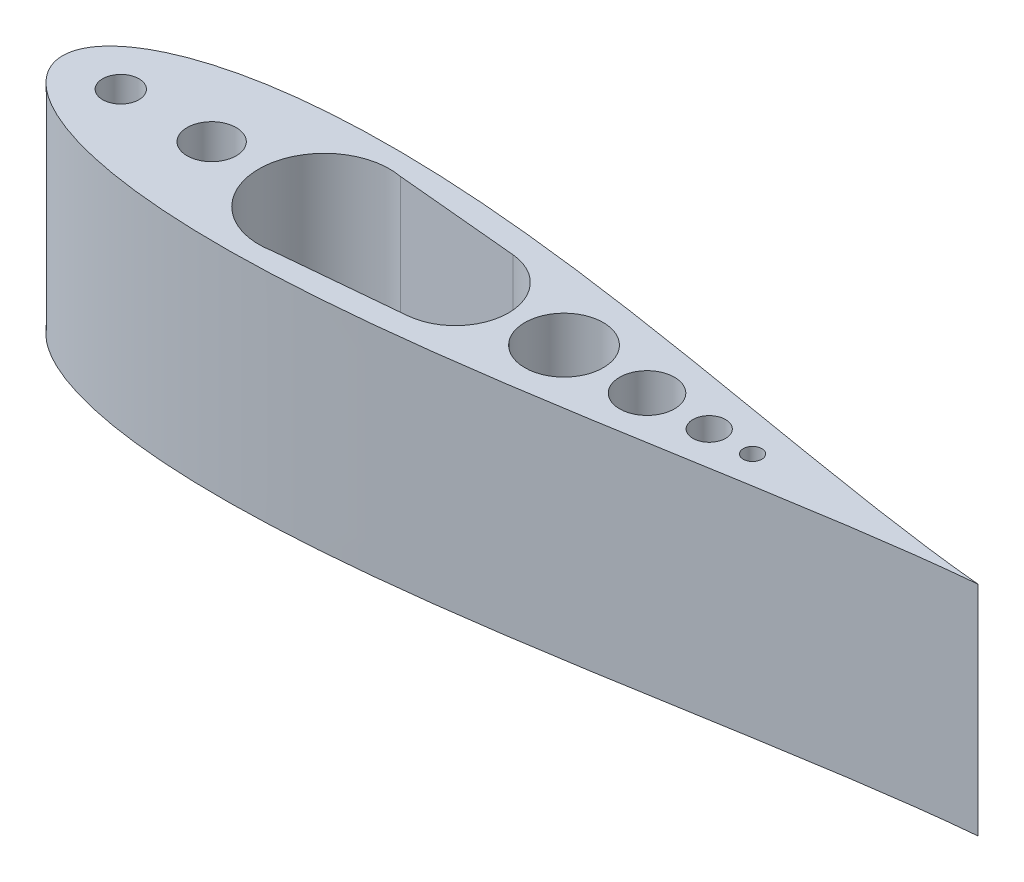
from build123d import *

# Parameters (mm, degrees)
SKETCH1_R           = 5.715
SKETCH1_R_2         = 9.131011462
SKETCH1_R_3         = 6.392333333
SKETCH1_R_4         = 3.81
SKETCH1_R_5         = 2.159
BOSS_EXTRUDE1_DEPTH = 50.8


with BuildPart() as part:
    # Sketch1 → Boss-Extrude1 (new body)
    with BuildSketch(Plane(origin=(0, 0, 0), x_dir=(1, 0, 0), z_dir=(0, 1, 0))):
        with BuildLine():
            add(Edge.make_bspline(
                [(-106.482983395, 7e-09), (-106.481988205, 0.336221447), (-106.427915569, 1.172470852), (-106.105951464, 2.643099269), (-105.314009735, 4.475217408), (-103.897531119, 6.504348419), (-101.808045378, 8.571651332), (-99.066717841, 10.567556704), (-95.719803188, 12.4267473), (-91.817332429, 14.111441711), (-87.406701835, 15.599318162), (-82.531907012, 16.877133323), (-77.234149654, 17.93743562), (-71.552607098, 18.776740572), (-65.525147606, 19.395460586), (-59.188591418, 19.79657403), (-52.57905308, 19.986276316), (-45.732001964, 19.972865837), (-38.682363694, 19.76732247), (-31.464522928, 19.382552478), (-24.112335149, 18.833317467), (-16.659115821, 18.136000968), (-9.137634043, 17.308302017), (-1.580112881, 16.368906014), (5.98177291, 15.337213534), (13.516891029, 14.232999407), (20.994645609, 13.076129848), (28.384968739, 11.886210001), (35.658323251, 10.682336314), (42.785702907, 9.482759124), (49.738647425, 8.304637787), (56.489265684, 7.163760718), (63.010281114, 6.074356699), (69.275076728, 5.048841412), (75.257781106, 4.097692071), (80.933343311, 3.229317249), (86.277669376, 2.449846213), (91.267618323, 1.763292049), (95.881607116, 1.17122476), (100.098099776, 0.673119164), (103.673185129, 0.290516392), (105.83614122, 0.081745654), (106.733370691, 7e-09)],
                knots=[0.5, 0.5, 0.5, 0.5, 0.502166769, 0.505390167, 0.509655974, 0.514947682, 0.521244711, 0.528520886, 0.536744945, 0.54588136, 0.555890751, 0.566730119, 0.57835299, 0.590709588, 0.603747039, 0.617409572, 0.631638768, 0.646373793, 0.661551658, 0.677107483, 0.692974771, 0.709085713, 0.725371443, 0.741762353, 0.758188398, 0.774579367, 0.790865214, 0.806976332, 0.822843867, 0.838400002, 0.853578262, 0.868313774, 0.882543568, 0.896206835, 0.909245173, 0.92160287, 0.933227116, 0.944068236, 0.954079898, 0.963219316, 0.971447445, 0.977251074, 0.977251074, 0.977251074, 0.977251074], degree=3))
            add(Edge.make_bspline(
                [(-106.482983395, -7e-09), (-106.481988205, -0.336221447), (-106.427915569, -1.172470852), (-106.105951463, -2.643099269), (-105.314009735, -4.475217408), (-103.897531118, -6.504348419), (-101.808045378, -8.571651332), (-99.06671784, -10.567556704), (-95.719803188, -12.4267473), (-91.817332429, -14.111441711), (-87.406701835, -15.599318162), (-82.531907011, -16.877133323), (-77.234149654, -17.93743562), (-71.552607098, -18.776740572), (-65.525147605, -19.395460586), (-59.188591417, -19.79657403), (-52.57905308, -19.986276316), (-45.732001964, -19.972865837), (-38.682363694, -19.76732247), (-31.464522928, -19.382552478), (-24.112335148, -18.833317467), (-16.659115821, -18.136000968), (-9.137634043, -17.308302017), (-1.580112881, -16.368906014), (5.98177291, -15.337213534), (13.516891029, -14.232999407), (20.99464561, -13.076129848), (28.384968739, -11.886210001), (35.658323251, -10.682336314), (42.785702907, -9.482759124), (49.738647426, -8.304637787), (56.489265684, -7.163760718), (63.010281115, -6.074356699), (69.275076728, -5.048841412), (75.257781106, -4.097692071), (80.933343311, -3.229317249), (86.277669376, -2.449846213), (91.267618323, -1.763292049), (95.881607116, -1.17122476), (100.098099776, -0.673119164), (103.673185129, -0.290516392), (105.83614122, -0.081745654), (106.733370691, -7e-09)],
                knots=[0.5, 0.5, 0.5, 0.5, 0.502166769, 0.505390167, 0.509655974, 0.514947682, 0.521244711, 0.528520886, 0.536744945, 0.54588136, 0.555890751, 0.566730119, 0.57835299, 0.590709588, 0.603747039, 0.617409572, 0.631638768, 0.646373793, 0.661551658, 0.677107483, 0.692974771, 0.709085713, 0.725371443, 0.741762353, 0.758188398, 0.774579367, 0.790865214, 0.806976332, 0.822843867, 0.838400002, 0.853578262, 0.868313774, 0.882543568, 0.896206835, 0.909245173, 0.92160287, 0.933227116, 0.944068236, 0.954079898, 0.963219316, 0.971447445, 0.977251074, 0.977251074, 0.977251074, 0.977251074], degree=3))
        make_face()
        with BuildLine():
            ThreePointArc((-88.703779951, 0), (-92.937113284, -4.233333333), (-97.170446617, 0))
            ThreePointArc((-97.170446617, 0), (-92.937113284, 4.233333333), (-88.703779951, 0))
        make_face(mode=Mode.SUBTRACT)
        with Locations((-71.77044662, 0)):
            Circle(SKETCH1_R, mode=Mode.SUBTRACT)
        with BuildLine():
            ThreePointArc((-45.540838593, -15.24), (-60.780838593, 0), (-45.540838593, 15.24))
            ThreePointArc((-45.540838593, 15.24), (-44.126098565, 15.174192257), (-42.723576496, 14.977337356))
            Line((-42.723576496, 14.977337356), (-13.847320134, 12.285108666))
            ThreePointArc((-13.847320134, 12.285108666), (-2.65431439, 0), (-13.847320134, -12.285108666))
            Line((-13.847320134, -12.285108666), (-42.723576496, -14.977337356))
            ThreePointArc((-42.723576496, -14.977337356), (-44.126098565, -15.174192257), (-45.540838593, -15.24))
        make_face(mode=Mode.SUBTRACT)
        with Locations((10.310172634, 0)):
            Circle(SKETCH1_R_2, mode=Mode.SUBTRACT)
        with Locations((29.643517429, 0)):
            Circle(SKETCH1_R_3, mode=Mode.SUBTRACT)
        with Locations((44.126269567, 0)):
            Circle(SKETCH1_R_4, mode=Mode.SUBTRACT)
        with Locations((54.210398224, 0)):
            Circle(SKETCH1_R_5, mode=Mode.SUBTRACT)
    extrude(amount=BOSS_EXTRUDE1_DEPTH)


solid = part.part
